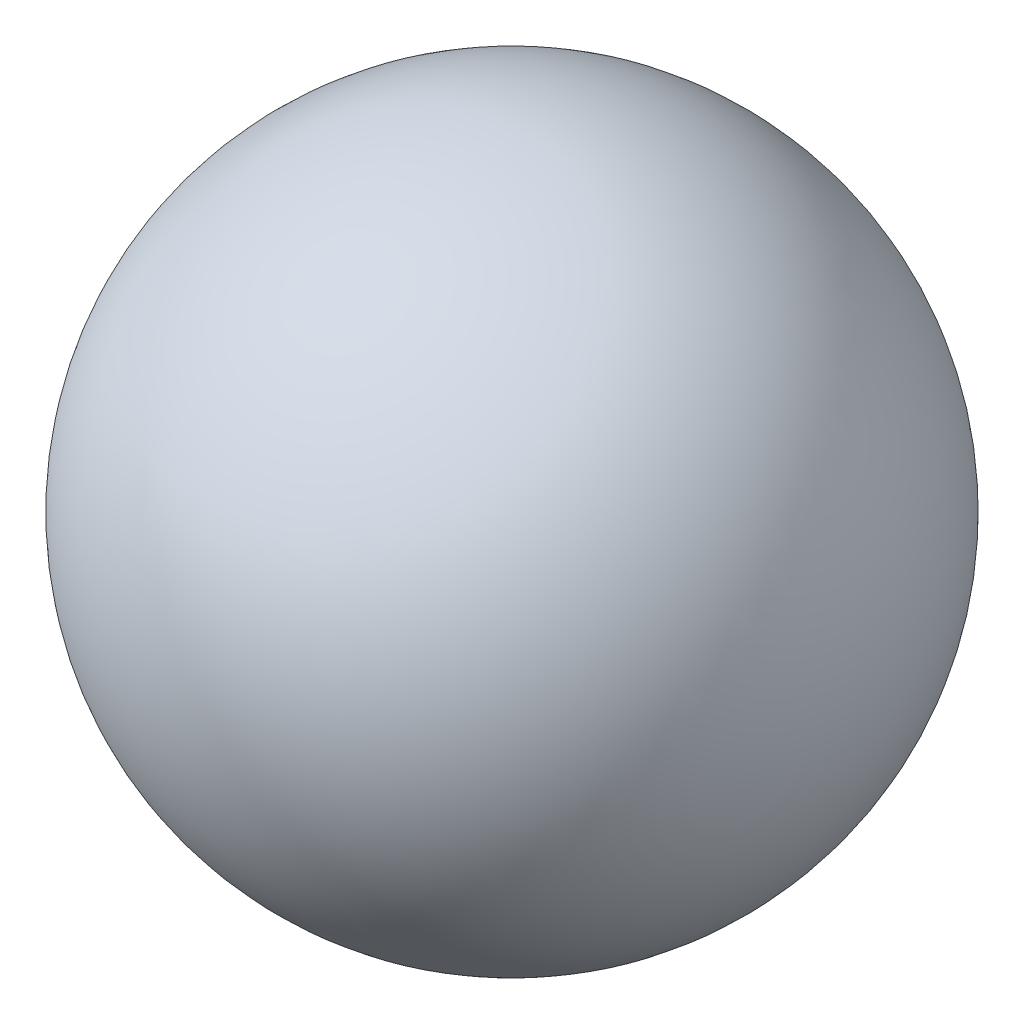
from build123d import *


with BuildPart() as part:
    # Sketch1 → Revolve1 (revolve)
    with BuildSketch(Plane.XY):
        with BuildLine():
            Line((0, -120.65), (0, 120.65))
            ThreePointArc((0, 120.65), (120.65, 0), (0, -120.65))
        make_face()
    revolve(axis=Axis((0, -120.65, 0), (0, 1, 0)))


solid = part.part
